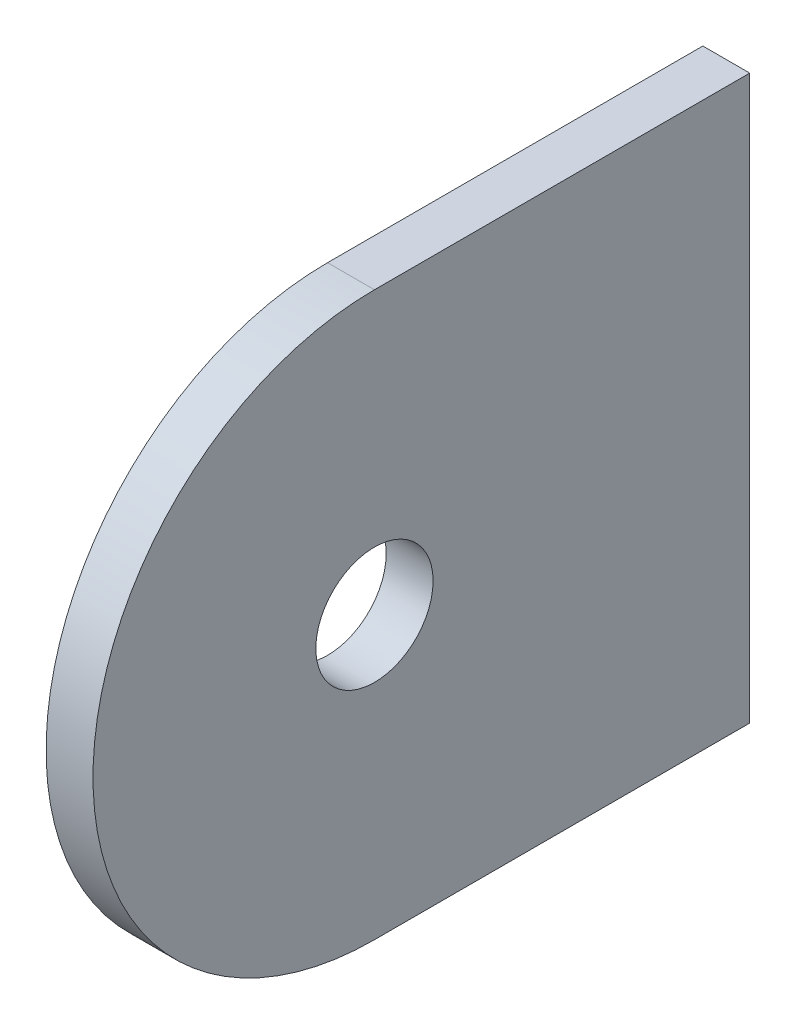
from build123d import *

# Parameters (mm, degrees)
SKETCH1_R           = 3.96875
BOSS_EXTRUDE1_DEPTH = 1.5875


with BuildPart() as part:
    # Sketch1 → Boss-Extrude1 (new body, symmetric)
    with BuildSketch(Plane(origin=(0, 0, 0), x_dir=(0, 0, -1), z_dir=(1, 0, 0))):
        with BuildLine():
            Line((-25.4, -19.05), (0, -19.05))
            Line((0, -19.05), (0, 19.05))
            Line((0, 19.05), (-25.4, 19.05))
            ThreePointArc((-25.4, 19.05), (-44.45, 0), (-25.4, -19.05))
        make_face()
        with Locations((-25.4, 0)):
            Circle(SKETCH1_R, mode=Mode.SUBTRACT)
    extrude(amount=BOSS_EXTRUDE1_DEPTH, both=True)


solid = part.part
